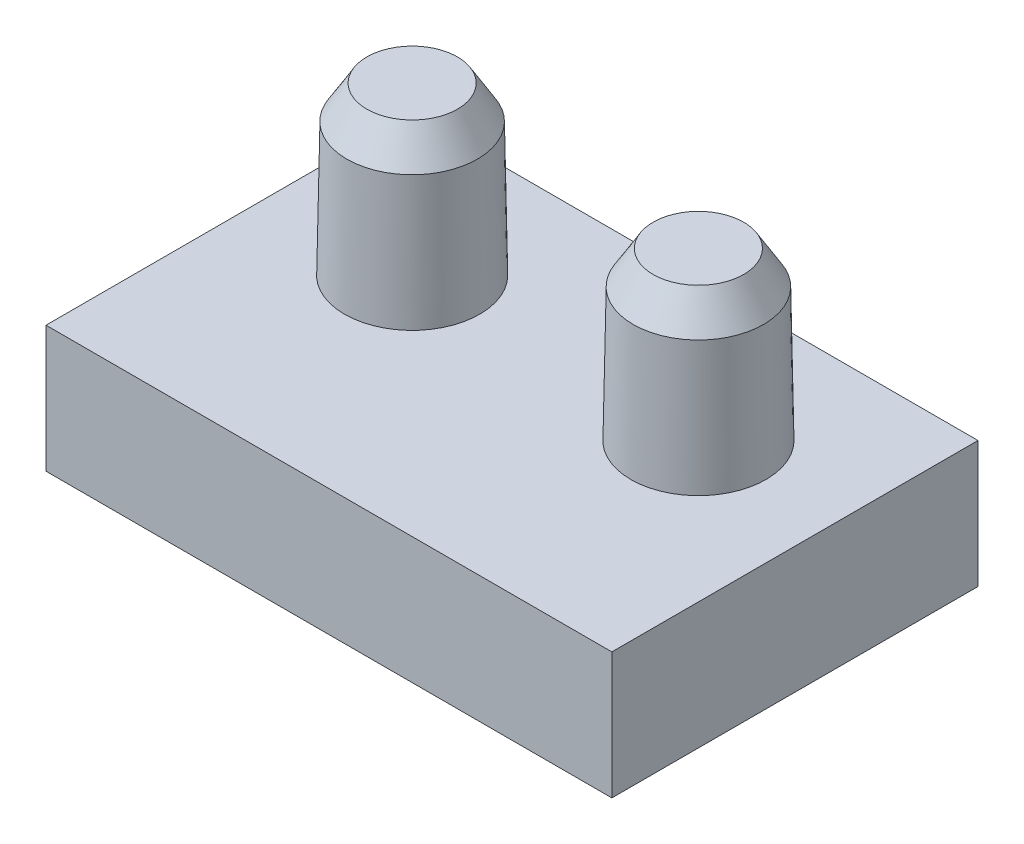
from build123d import *
from OCP.BRepFilletAPI import BRepFilletAPI_MakeChamfer

# Parameters (mm, degrees)
SKETCH1_W                     = 8.5
SKETCH1_H                     = 5.5
BOSS_EXTRUDE1_DEPTH           = 1.9
BOSS_EXTRUDE2_REACH           = 8.307
BOSS_EXTRUDE2_START           = 0.9
SKETCH2_R                     = 1
BOSS_EXTRUDE2_DRAFT           = 1
BOSS_EXTRUDE3_START           = 0.9
SKETCH2_2_R                   = 1
BOSS_EXTRUDE3_DEPTH           = 1.6
BOSS_EXTRUDE3_DRAFT           = 1
BOSS_EXTRUDE3_PROFILE_2_DEPTH = 1.6
BOSS_EXTRUDE3_PROFILE_2_DRAFT = 1
CHAMFER1_SIZE                 = 0.5
CHAMFER1_SIZE2                = 0.291658349


with BuildPart() as part:
    # Sketch1 → Boss-Extrude1 (new body)
    with BuildSketch(Plane(origin=(0, 0, 0), x_dir=(1, 0, 0), z_dir=(0, 1, 0))):
        Rectangle(SKETCH1_W, SKETCH1_H)
    extrude(amount=BOSS_EXTRUDE1_DEPTH)




with BuildPart() as boss_extrude2_long_prism_1:
    # Sketch2 → Boss-Extrude2 (the long prism of profile 1, to be tilted and cut off)
    with BuildSketch(Plane(origin=(0, 1.9, 0), x_dir=(1, 0, 0), z_dir=(0, 1, 0)).offset(BOSS_EXTRUDE2_START)):
        with Locations((-2.15, 0.65)):
            Circle(SKETCH2_R)
    extrude(amount=-BOSS_EXTRUDE2_REACH)
    boss_extrude2_tool1_sides = [boss_extrude2_long_prism_1.faces().sort_by_distance(p)[0] for p in [
        (-3.15, -1.3535, -0.65),
    ]]
    draft(boss_extrude2_tool1_sides, Plane(origin=(0, 1.9, 0), x_dir=(1, 0, 0), z_dir=(0, 1, 0)).offset(BOSS_EXTRUDE2_START), BOSS_EXTRUDE2_DRAFT)  # the draft: side faces tilted about the start plane


with BuildPart() as part_1:
    add(part.part)
    boss_extrude2_tool1 = boss_extrude2_long_prism_1.part - part.part



with BuildPart() as boss_extrude2_long_prism_2:
    # Sketch2 → Boss-Extrude2 (the long prism of profile 2, to be tilted and cut off)
    with BuildSketch(Plane(origin=(0, 1.9, 0), x_dir=(1, 0, 0), z_dir=(0, 1, 0)).offset(BOSS_EXTRUDE2_START)):
        with Locations((2.15, 0.65)):
            Circle(SKETCH2_R)
    extrude(amount=-BOSS_EXTRUDE2_REACH)
    boss_extrude2_tool2_sides = [boss_extrude2_long_prism_2.faces().sort_by_distance(p)[0] for p in [
        (1.15, -1.3535, -0.65),
    ]]
    draft(boss_extrude2_tool2_sides, Plane(origin=(0, 1.9, 0), x_dir=(1, 0, 0), z_dir=(0, 1, 0)).offset(BOSS_EXTRUDE2_START), BOSS_EXTRUDE2_DRAFT)  # the draft: side faces tilted about the start plane


with BuildPart() as part_2:
    add(part_1.part)
    boss_extrude2_tool2 = boss_extrude2_long_prism_2.part - part.part
    add(boss_extrude2_tool1.solids().sort_by_distance((-2.15, 2.8, -0.65))[0])
    add(boss_extrude2_tool2.solids().sort_by_distance((2.15, 2.8, -0.65))[0])


with BuildPart() as boss_extrude3_tool:
    # Sketch2_2 → Boss-Extrude3 (with draft: the straight prism first)
    with BuildSketch(Plane(origin=(0, 1.9, 0), x_dir=(1, 0, 0), z_dir=(0, 1, 0)).offset(BOSS_EXTRUDE3_START)):
        with Locations((-2.15, 0.65)):
            Circle(SKETCH2_2_R)
    extrude(amount=BOSS_EXTRUDE3_DEPTH)
    # Boss-Extrude3: the draft: its side faces are tilted about the plane it starts from
    boss_extrude3_sides = [boss_extrude3_tool.faces().sort_by_distance(p)[0] for p in [
        (-3.15, 3.6, -0.65),
    ]]
    draft(boss_extrude3_sides, Plane(origin=(0, 1.9, 0), x_dir=(1, 0, 0), z_dir=(0, 1, 0)).offset(BOSS_EXTRUDE3_START), BOSS_EXTRUDE3_DRAFT)


with BuildPart() as part_3:
    add(part_2.part)

    # Boss-Extrude3: add boss_extrude3_tool
    add(boss_extrude3_tool.part)


with BuildPart() as boss_extrude3_profile_2_tool:
    # Sketch2_2 → Boss-Extrude3 profile 2 (with draft: the straight prism first)
    with BuildSketch(Plane(origin=(0, 1.9, 0), x_dir=(1, 0, 0), z_dir=(0, 1, 0)).offset(BOSS_EXTRUDE3_START)):
        with Locations((2.15, 0.65)):
            Circle(SKETCH2_2_R)
    extrude(amount=BOSS_EXTRUDE3_PROFILE_2_DEPTH)
    # Boss-Extrude3 profile 2: the draft: its side faces are tilted about the plane it starts from
    boss_extrude3_profile_2_sides = [boss_extrude3_profile_2_tool.faces().sort_by_distance(p)[0] for p in [
        (1.15, 3.6, -0.65),
    ]]
    draft(boss_extrude3_profile_2_sides, Plane(origin=(0, 1.9, 0), x_dir=(1, 0, 0), z_dir=(0, 1, 0)).offset(BOSS_EXTRUDE3_START), BOSS_EXTRUDE3_PROFILE_2_DRAFT)


with BuildPart() as part_4:
    add(part_3.part)

    # Boss-Extrude3 profile 2: add boss_extrude3_profile_2_tool
    add(boss_extrude3_profile_2_tool.part)

    # Chamfer1: one chamfer whose edges measure the first distance from different faces: ONE call of the kernel's chamfer builder (chamfer() names one face for all edges)
    chamfer1_edges_1 = [part_4.edges().sort_by_distance(p)[0] for p in [
        (-3.122071896, 4.4, -0.65),
    ]]
    chamfer1_side_1 = [part_4.faces().sort_by_distance(p)[0] for p in [
        (-3.143890727, 3.15, -0.65),
    ]]
    chamfer1_edges_2 = [part_4.edges().sort_by_distance(p)[0] for p in [
        (1.177928104, 4.4, -0.65),
    ]]
    chamfer1_side_2 = [part_4.faces().sort_by_distance(p)[0] for p in [
        (1.156109273, 3.15, -0.65),
    ]]
    chamfer1 = BRepFilletAPI_MakeChamfer(part_4.part.solid().wrapped)
    for e in chamfer1_edges_1:
        chamfer1.Add(CHAMFER1_SIZE, CHAMFER1_SIZE2, e.wrapped, chamfer1_side_1[0].wrapped)  # the first distance lies on this face
    for e in chamfer1_edges_2:
        chamfer1.Add(CHAMFER1_SIZE, CHAMFER1_SIZE2, e.wrapped, chamfer1_side_2[0].wrapped)  # the first distance lies on this face
    add(Compound.cast(chamfer1.Shape()), mode=Mode.REPLACE)


solid = part_4.part
